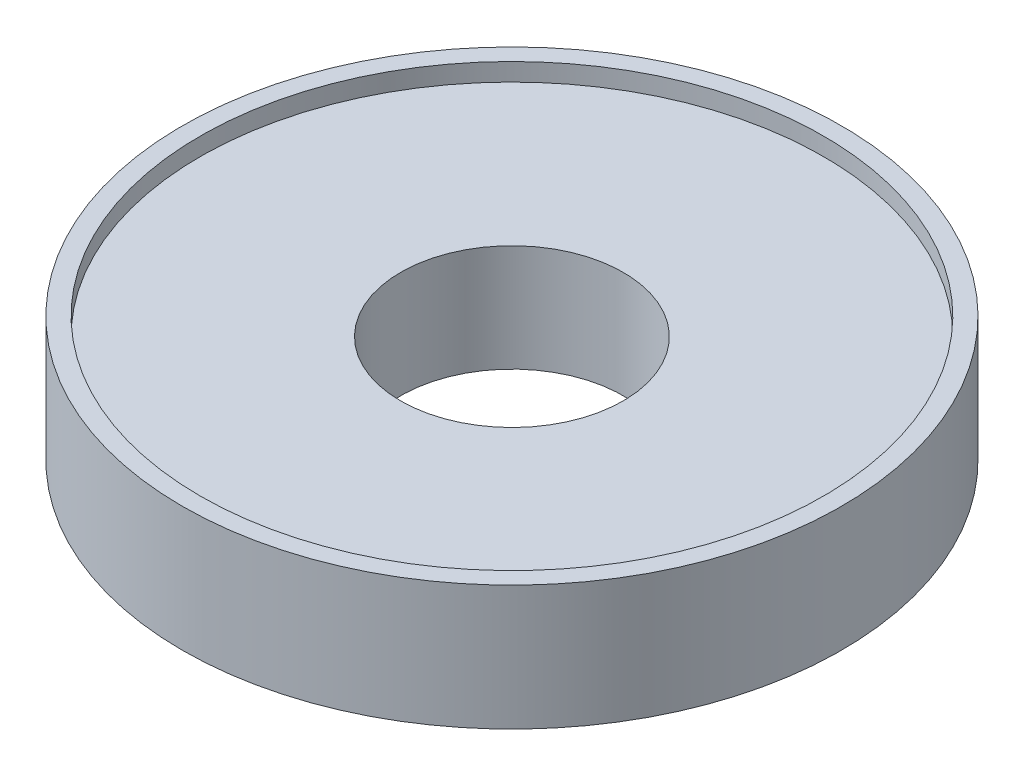
from build123d import *

# Parameters (mm, degrees)
SKETCH1_R              = 18.5
BOSS_EXTRUDE1_DEPTH    = 6
SKETCH2_R              = 18.5
SKETCH2_R_2            = 17.5
BOSS_EXTRUDE2_DEPTH    = 1
M14X1_5_TAPPED_HOLE1_D = 12.5
SKETCH5_R              = 2.25
CUT_EXTRUDE1_DEPTH     = 4


with BuildPart() as part:
    # Sketch1 → Boss-Extrude1 (new body)
    with BuildSketch(Plane(origin=(0, 0, 0), x_dir=(1, 0, 0), z_dir=(0, 1, 0))):
        Circle(SKETCH1_R)
    extrude(amount=BOSS_EXTRUDE1_DEPTH)

    # Sketch2 → Boss-Extrude2 (add)
    with BuildSketch(Plane(origin=(0, 6, 0), x_dir=(1, 0, 0), z_dir=(0, 1, 0))):
        Circle(SKETCH2_R)
        Circle(SKETCH2_R_2, mode=Mode.SUBTRACT)
    extrude(amount=BOSS_EXTRUDE2_DEPTH)

    # M14x1.5 Tapped Hole1 (through all)
    with Locations(Plane(origin=(0, 6, 0), x_dir=(1, 0, 0), z_dir=(0, 1, 0))):
        with Locations((0, 0)):
            Hole(M14X1_5_TAPPED_HOLE1_D / 2)

    # Sketch5 → Cut-Extrude1 (cut)
    with BuildSketch(Plane.XZ):
        with Locations((-10.606601718, 10.606601718)):
            Circle(SKETCH5_R)
        with Locations((10.606601718, 10.606601718)):
            Circle(SKETCH5_R)
        with Locations((10.606601718, -10.606601718)):
            Circle(SKETCH5_R)
        with Locations((-10.606601718, -10.606601718)):
            Circle(SKETCH5_R)
    extrude(amount=-CUT_EXTRUDE1_DEPTH, mode=Mode.SUBTRACT)


solid = part.part
